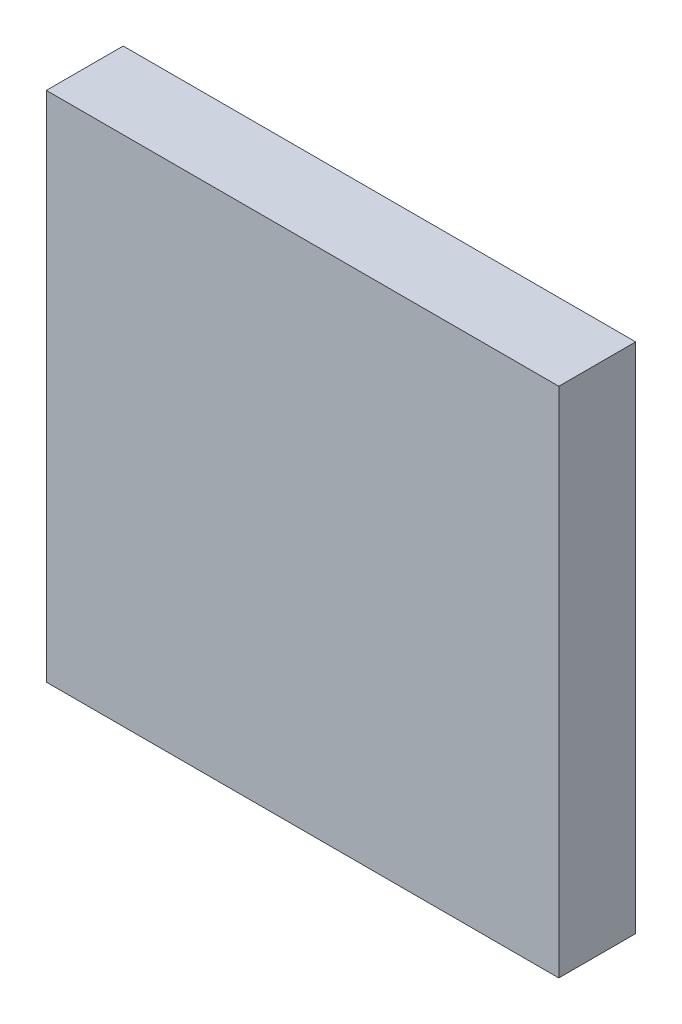
from build123d import *

# Parameters (mm, degrees)
SKETCH1_W           = 200
SKETCH1_H           = 200
SKETCH1_R           = 10
BOSS_EXTRUDE1_DEPTH = 30
BOSS_EXTRUDE2_START = -10
SKETCH2_R           = 10
BOSS_EXTRUDE2_DEPTH = 20


with BuildPart() as part:
    # Sketch1 → Boss-Extrude1 (new body)
    with BuildSketch(Plane.XY):
        with Locations((100, 100)):
            Rectangle(SKETCH1_W, SKETCH1_H)
        with Locations((145, 130)):
            Circle(SKETCH1_R, mode=Mode.SUBTRACT)
        with Locations((55, 130)):
            Circle(SKETCH1_R, mode=Mode.SUBTRACT)
    extrude(amount=BOSS_EXTRUDE1_DEPTH)

    # Sketch2 → Boss-Extrude2 (add)
    with BuildSketch(Plane(origin=(0, 0, 0), x_dir=(-1, 0, 0), z_dir=(0, 0, -1)).offset(BOSS_EXTRUDE2_START)):
        with Locations((-145, 130)):
            Circle(SKETCH2_R)
        with Locations((-55, 130)):
            Circle(SKETCH2_R)
    extrude(amount=-BOSS_EXTRUDE2_DEPTH)


solid = part.part
